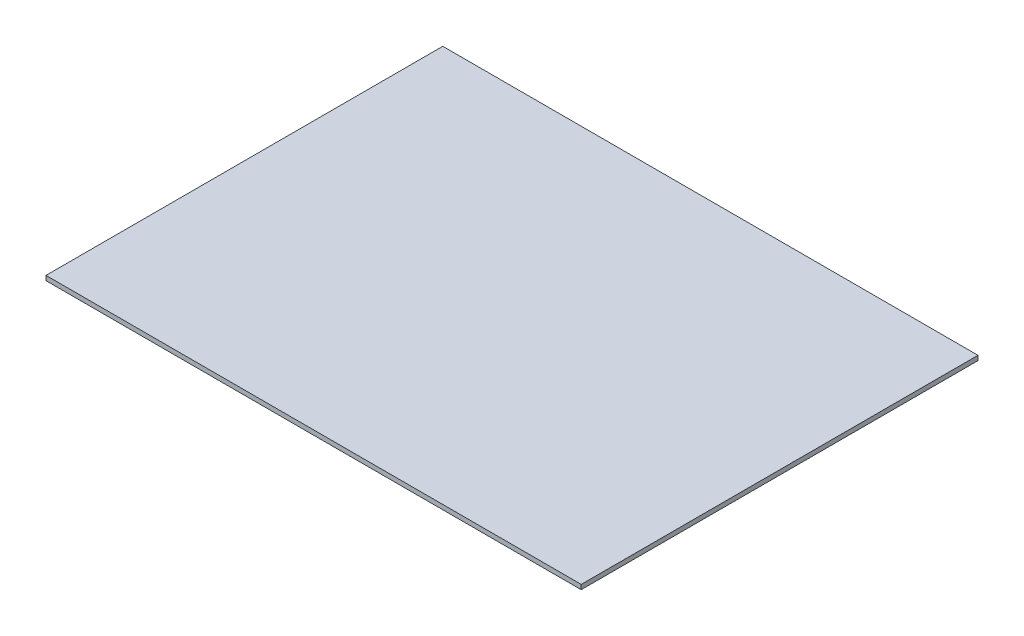
from build123d import *

# Parameters (mm, degrees)
CROQUIS1_W              = 348
CROQUIS1_H              = 258
SALIENTE_EXTRUIR1_DEPTH = 3


with BuildPart() as part:
    # Croquis1 → Saliente-Extruir1 (new body)
    with BuildSketch(Plane(origin=(0, 0, 0), x_dir=(1, 0, 0), z_dir=(0, 1, 0))):
        with Locations((174, 129)):
            Rectangle(CROQUIS1_W, CROQUIS1_H)
    extrude(amount=SALIENTE_EXTRUIR1_DEPTH)


solid = part.part
